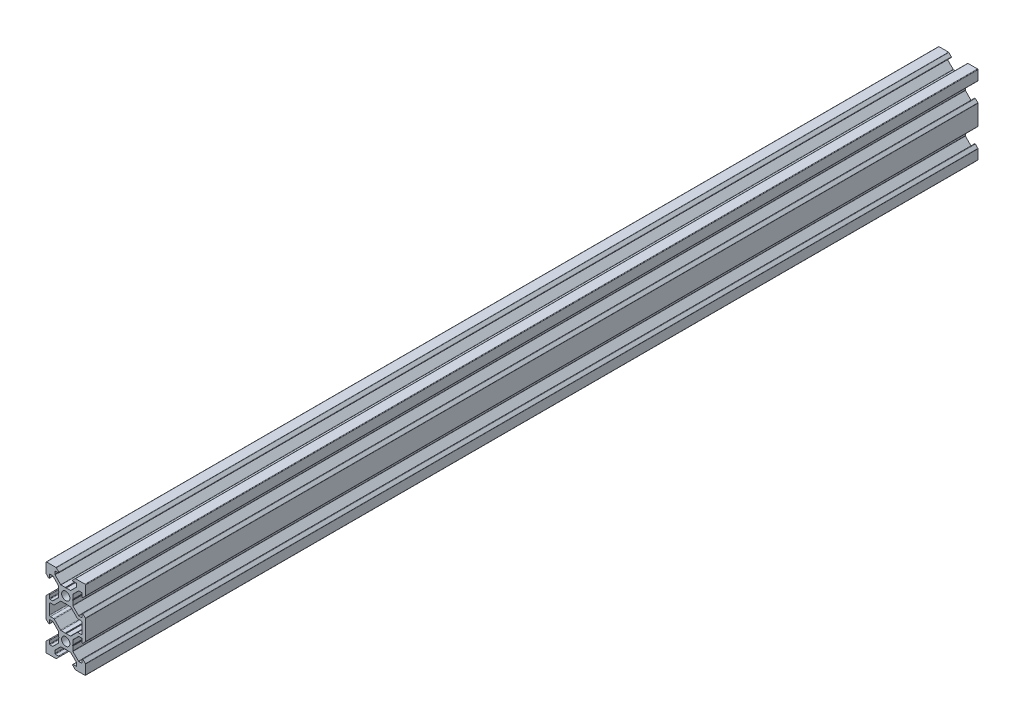
from build123d import *

# Parameters (mm, degrees)
SKETCH1_R           = 2.1
BOSS_EXTRUDE1_DEPTH = 452
FILLET1_R           = 0.25
FILLET2_R           = 0.5
CUT_EXTRUDE1_DEPTH  = 453


with BuildPart() as part:
    # Sketch1 → Boss-Extrude1 (new body)
    with BuildSketch(Plane.XY):
        Polygon((3.560660172, -2.5), (3.560660172, 2.5), (6.560660172, 5.5), (8.252142372, 5.5), (8.252142372, 3.1), (10, 4.847857628), (10, 10), (4.847857628, 10), (3.1, 8.252142372), (5.5, 8.252142372), (5.5, 6.560660172), (2.5, 3.560660172), (-2.5, 3.560660172), (-5.5, 6.560660172), (-5.5, 8.252142372), (-3.1, 8.252142372), (-4.847857628, 10), (-10, 10), (-10, 4.847857628), (-8.252142372, 3.1), (-8.252142372, 5.5), (-6.560660172, 5.5), (-3.560660172, 2.5), (-3.560660172, -2.5), (-6.560660172, -5.5), (-8.252142372, -5.5), (-8.252142372, -3.1), (-10, -4.847857628), (-10, -7), (-10, -13), (-10, -15.152142372), (-8.252142372, -16.9), (-8.252142372, -14.5), (-6.560660172, -14.5), (-3.560660172, -17.5), (-3.560660172, -22.5), (-6.560660172, -25.5), (-8.252142372, -25.5), (-8.252142372, -23.1), (-10, -24.847857628), (-10, -30), (-4.847857628, -30), (-3.1, -28.252142372), (-5.5, -28.252142372), (-5.5, -26.560660172), (-2.5, -23.560660172), (2.5, -23.560660172), (5.5, -26.560660172), (5.5, -28.252142372), (3.1, -28.252142372), (4.847857628, -30), (10, -30), (10, -24.847857628), (8.252142372, -23.1), (8.252142372, -25.5), (6.560660172, -25.5), (3.560660172, -22.5), (3.560660172, -17.5), (6.560660172, -14.5), (8.252142372, -14.5), (8.252142372, -16.9), (10, -15.152142372), (10, -13), (10, -7), (10, -4.847857628), (8.252142372, -3.1), (8.252142372, -5.5), (6.560660172, -5.5), align=None)
        Circle(SKETCH1_R, mode=Mode.SUBTRACT)
        with Locations((0, -20)):
            Circle(SKETCH1_R, mode=Mode.SUBTRACT)
        Polygon((2.5, -3.560660172), (-2.5, -3.560660172), (-5.5, -6.560660172), (-5.939339828, -7), (-8.252142372, -7), (-8.252142372, -13), (-5.939339828, -13), (-5.5, -13.439339828), (-2.5, -16.439339828), (2.5, -16.439339828), (5.5, -13.439339828), (5.939339828, -13), (8.252142372, -13), (8.252142372, -7), (5.939339828, -7), (5.5, -6.560660172), align=None, mode=Mode.SUBTRACT)
    extrude(amount=BOSS_EXTRUDE1_DEPTH)

    # Fillet1
    fillet1_edges = [part.edges().sort_by_distance(p)[0] for p in [
        (5.5, 6.560660172, 226),
        (5.5, 8.252142372, 226),
        (3.1, 8.252142372, 226),
        (4.847857628, 10, 226),
        (10, 10, 226),
        (10, 4.847857628, 226),
        (8.252142372, 3.1, 226),
        (8.252142372, 5.5, 226),
        (6.560660172, 5.5, 226),
        (3.560660172, 2.5, 226),
        (3.560660172, -2.5, 226),
        (6.560660172, -5.5, 226),
        (8.252142372, -5.5, 226),
        (8.252142372, -3.1, 226),
        (10, -4.847857628, 226),
        (10, -15.152142372, 226),
        (8.252142372, -16.9, 226),
        (8.252142372, -14.5, 226),
        (6.560660172, -14.5, 226),
        (3.560660172, -17.5, 226),
        (3.560660172, -22.5, 226),
        (6.560660172, -25.5, 226),
        (8.252142372, -25.5, 226),
        (8.252142372, -23.1, 226),
        (10, -24.847857628, 226),
        (10, -30, 226),
        (4.847857628, -30, 226),
        (3.1, -28.252142372, 226),
        (5.5, -28.252142372, 226),
        (5.5, -26.560660172, 226),
        (2.5, -23.560660172, 226),
        (-2.5, -23.560660172, 226),
        (-5.5, -26.560660172, 226),
        (-5.5, -28.252142372, 226),
        (-3.1, -28.252142372, 226),
        (-4.847857628, -30, 226),
        (-10, -30, 226),
        (-10, -24.847857628, 226),
        (-8.252142372, -23.1, 226),
        (-8.252142372, -25.5, 226),
        (-6.560660172, -25.5, 226),
        (-3.560660172, -22.5, 226),
        (-3.560660172, -17.5, 226),
        (-6.560660172, -14.5, 226),
        (-8.252142372, -14.5, 226),
        (-8.252142372, -16.9, 226),
        (-10, -15.152142372, 226),
        (-10, -4.847857628, 226),
        (-8.252142372, -3.1, 226),
        (-8.252142372, -5.5, 226),
        (-6.560660172, -5.5, 226),
        (-3.560660172, -2.5, 226),
        (-3.560660172, 2.5, 226),
        (-6.560660172, 5.5, 226),
        (-8.252142372, 5.5, 226),
        (-8.252142372, 3.1, 226),
        (-10, 4.847857628, 226),
        (-10, 10, 226),
        (-4.847857628, 10, 226),
        (-3.1, 8.252142372, 226),
        (-5.5, 8.252142372, 226),
        (-5.5, 6.560660172, 226),
        (-2.5, 3.560660172, 226),
        (2.5, 3.560660172, 226),
    ]]
    fillet(fillet1_edges, radius=FILLET1_R)

    # Fillet2
    fillet2_edges = [part.edges().sort_by_distance(p)[0] for p in [
        (-2.5, -3.560660172, 226),
        (-5.939339828, -7, 226),
        (-8.252142372, -7, 226),
        (-8.252142372, -13, 226),
        (-5.939339828, -13, 226),
        (-2.5, -16.439339828, 226),
        (2.5, -16.439339828, 226),
        (5.939339828, -13, 226),
        (8.252142372, -13, 226),
        (8.252142372, -7, 226),
        (5.939339828, -7, 226),
        (2.5, -3.560660172, 226),
    ]]
    fillet(fillet2_edges, radius=FILLET2_R)

    # Sketch2 → Cut-Extrude1 (cut, through all)
    with BuildSketch(Plane.XY.offset(452)):
        Polygon((0, 3.398953432), (-0.242280927, 3.560660172), (0.242280927, 3.560660172), align=None)
        Polygon((0, -3.398953432), (0.242280927, -3.560660172), (-0.242280927, -3.560660172), align=None)
        Polygon((3.560660172, 0.242280927), (3.560660172, -0.242280927), (3.398953432, 0), align=None)
        Polygon((-3.560660172, 0.242280927), (-3.560660172, -0.242280927), (-3.398953432, 0), align=None)
        Polygon((-3.398953432, -20), (-3.560660172, -20.242280927), (-3.560660172, -19.757719073), align=None)
        Polygon((3.398953432, -20), (3.560660172, -19.757719073), (3.560660172, -20.242280927), align=None)
        Polygon((-0.242280927, -16.439339828), (0.242280927, -16.439339828), (0, -16.601046568), align=None)
        Polygon((-0.242280927, -23.560660172), (0.242280927, -23.560660172), (0, -23.398953432), align=None)
    extrude(amount=-CUT_EXTRUDE1_DEPTH, mode=Mode.SUBTRACT)


solid = part.part
